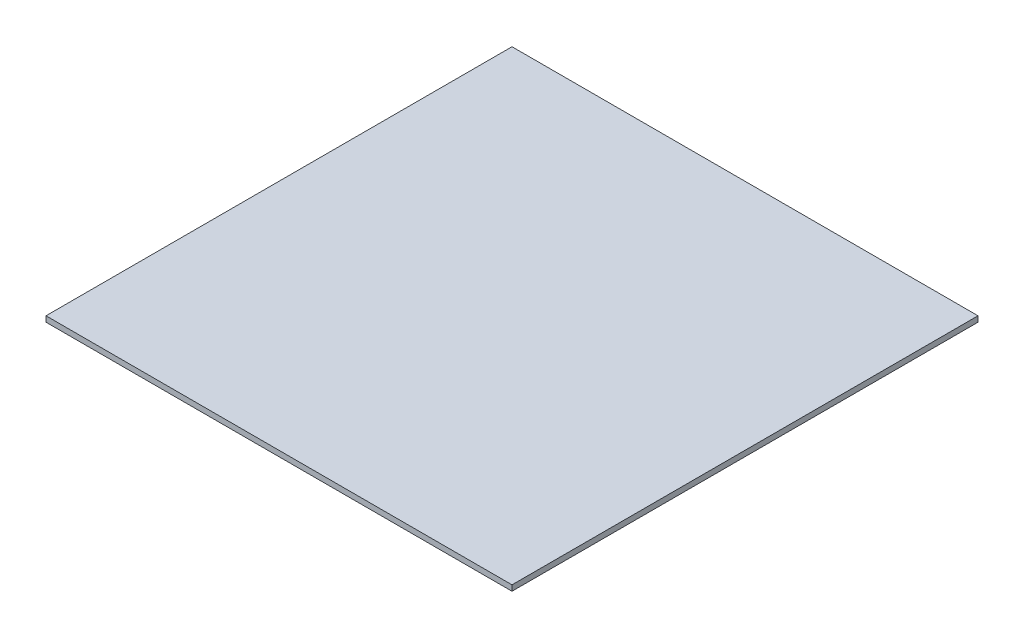
from build123d import *

# Parameters (mm, degrees)
SKETCH1_W           = 500
SKETCH1_H           = 500
BOSS_EXTRUDE1_DEPTH = 6


with BuildPart() as part:
    # Sketch1 → Boss-Extrude1 (new body)
    with BuildSketch(Plane(origin=(0, 0, 0), x_dir=(1, 0, 0), z_dir=(0, 1, 0))):
        Rectangle(SKETCH1_W, SKETCH1_H)
    extrude(amount=BOSS_EXTRUDE1_DEPTH)


solid = part.part
